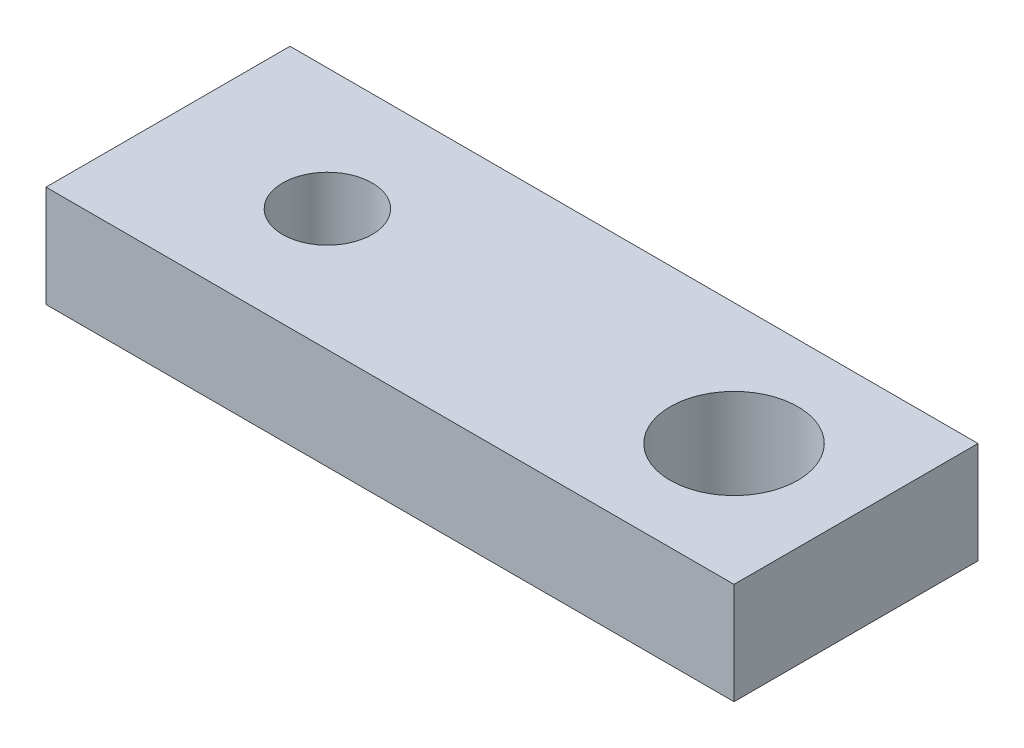
from build123d import *

# Parameters (mm, degrees)
SKETCH1_W           = 21.4884
SKETCH1_H           = 7.62
SKETCH1_R           = 1.397
SKETCH1_R_2         = 1.9939
BOSS_EXTRUDE3_DEPTH = 3.175


with BuildPart() as part:
    # Sketch1 → Boss-Extrude3 (new body)
    with BuildSketch(Plane(origin=(0, 0, 0), x_dir=(1, 0, 0), z_dir=(0, 1, 0))):
        with Locations((5.7658, 0)):
            Rectangle(SKETCH1_W, SKETCH1_H)
        Circle(SKETCH1_R, mode=Mode.SUBTRACT)
        with Locations((12.7, 0)):
            Circle(SKETCH1_R_2, mode=Mode.SUBTRACT)
    extrude(amount=BOSS_EXTRUDE3_DEPTH)


solid = part.part
